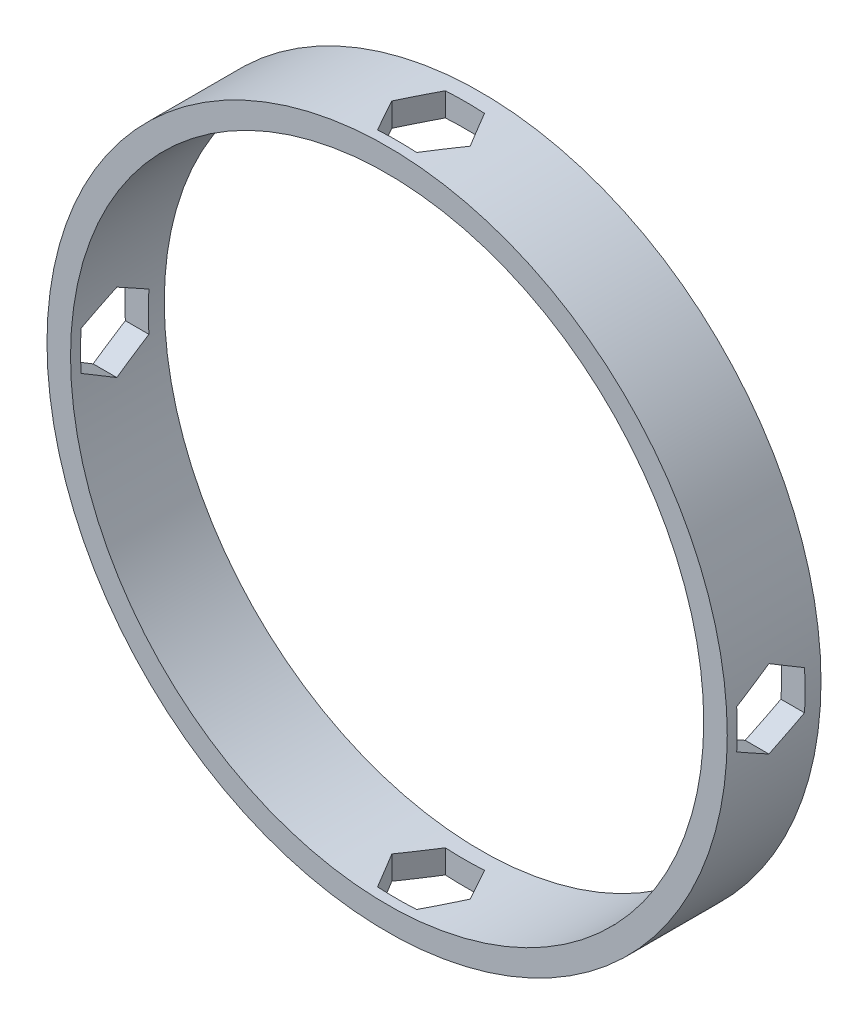
from build123d import *

# Parameters (mm, degrees)
SKETCH1_R           = 34.11
SKETCH1_R_2         = 31.75
BOSS_EXTRUDE1_DEPTH = 9.4
CUT_EXTRUDE1_DEPTH  = 69.22
CIRPATTERN2_COUNT   = 2
CIRPATTERN2_ANGLE   = 90


with BuildPart() as part:
    # Sketch1 → Boss-Extrude1 (new body)
    with BuildSketch(Plane.XY):
        Circle(SKETCH1_R)
        Circle(SKETCH1_R_2, mode=Mode.SUBTRACT)
    extrude(amount=BOSS_EXTRUDE1_DEPTH)

    # Sketch2 → Cut-Extrude1 (cut, through all)
    with BuildSketch(Plane(origin=(0, 34.11, 0), x_dir=(1, 0, 0), z_dir=(0, 1, 0))):
        Polygon((3.92598183, -5), (1.962990915, -1.6), (-1.962990915, -1.6), (-3.92598183, -5), (-1.962990915, -8.4), (1.962990915, -8.4), align=None)
    cut_extrude1 = extrude(amount=-CUT_EXTRUDE1_DEPTH, mode=Mode.SUBTRACT)

    # CirPattern2: Cut-Extrude1 ×2 about axis
    cirpattern2_axis = Axis((0, 0, 9.4), (0, 0, 1))
    for i in range(1, CIRPATTERN2_COUNT):
        add(cut_extrude1.rotate(cirpattern2_axis, i * CIRPATTERN2_ANGLE / (CIRPATTERN2_COUNT - 1)), mode=Mode.SUBTRACT)


solid = part.part
